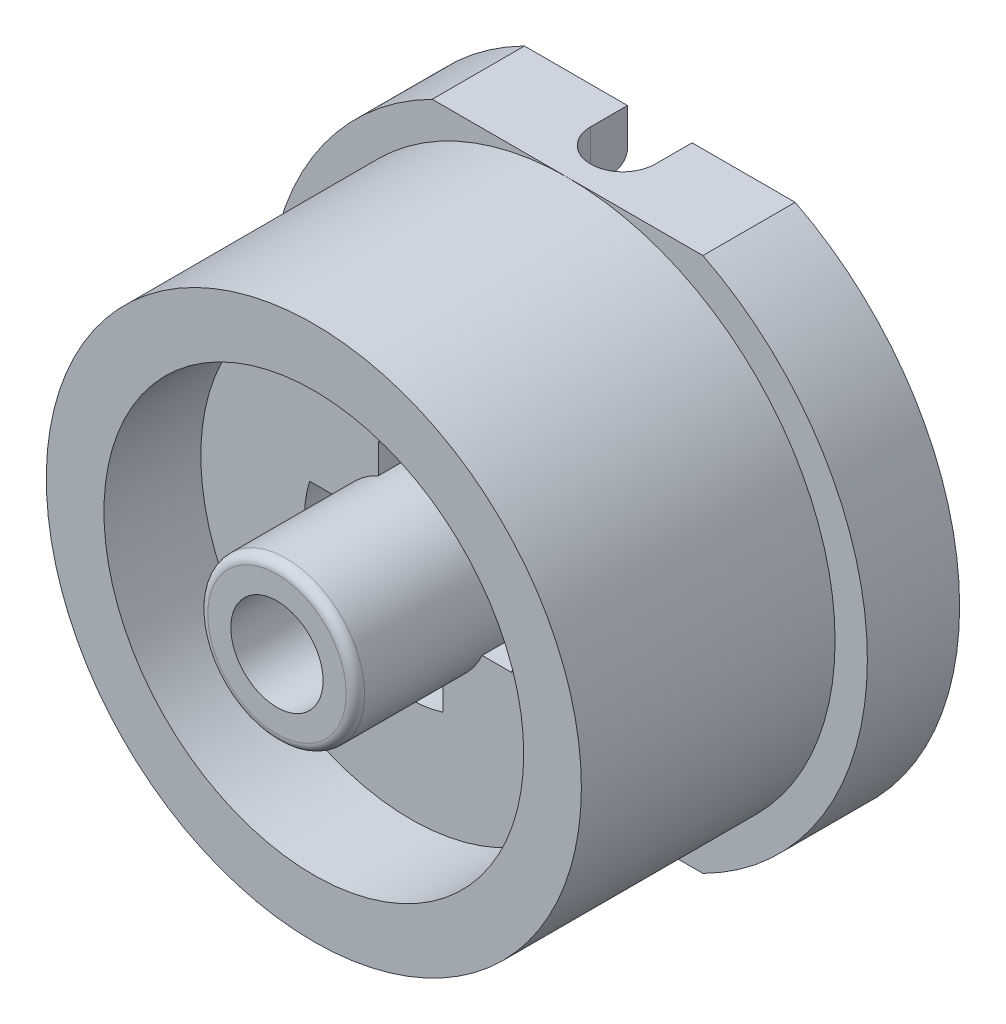
from build123d import *

# Parameters (mm, degrees)
SKETCH_1_R               = 5.8
SKETCH_1_R_2             = 4.55
EXTRUDE_1_DEPTH          = 2.1
SKETCH_1_3_R             = 1.7
SKETCH_1_3_R_2           = 1
EXTRUDE_2_DEPTH          = 2.9
SKETCH_1_5_R             = 5.8
SKETCH_1_5_R_2           = 4.55
SKETCH_1_5_R_3           = 1.7
SKETCH_1_5_R_4           = 1
EXTRUDE_4_DEPTH          = 0.8
SKETCH_2_R               = 5.8
SKETCH_2_R_2             = 4.75
EXTRUDE_5_DEPTH          = 4.6
EXTRUDE_6_DEPTH          = 2
CUT_EXTRUDE_1_REACH      = 11.851
FILLET_1_R               = 0.2
FILLET_2_R               = 0.3
SKETCH_6_R               = 1.15
CUT_EXTRUDE_4_DEPTH      = 0.5
CUT_EXTRUDE_5_REACH      = 16.352
CUT_EXTRUDE_5_END_RADIUS = 4.75


with BuildPart() as part:
    # Sketch 1 → Extrude 1 (new body)
    with BuildSketch(Plane.XY):
        Circle(SKETCH_1_R)
        Circle(SKETCH_1_R_2, mode=Mode.SUBTRACT)
    extrude(amount=EXTRUDE_1_DEPTH)



with BuildPart() as body_2:
    # Sketch 1_3 → Extrude 2 (new body)
    with BuildSketch(Plane.XY):
        Circle(SKETCH_1_3_R)
        Circle(SKETCH_1_3_R_2, mode=Mode.SUBTRACT)
    extrude(amount=EXTRUDE_2_DEPTH)


with BuildPart() as part_1:
    add(part.part)

    add(body_2.part)  # Extrude 4 merges body 2
    # Sketch 1_5 → Extrude 4 (add)
    with BuildSketch(Plane.XY):
        Circle(SKETCH_1_5_R)
        Circle(SKETCH_1_5_R_2, mode=Mode.SUBTRACT)
        Circle(SKETCH_1_5_R_2)
        Circle(SKETCH_1_5_R_3, mode=Mode.SUBTRACT)
        Circle(SKETCH_1_5_R_3)
        Circle(SKETCH_1_5_R_4, mode=Mode.SUBTRACT)
    extrude(amount=-EXTRUDE_4_DEPTH)

    # Sketch 2 → Extrude 5 (add)
    with BuildSketch(Plane(origin=(0, 0, -0.8), x_dir=(-1, 0, 0), z_dir=(0, 0, -1))):
        Circle(SKETCH_2_R)
        Circle(SKETCH_2_R_2, mode=Mode.SUBTRACT)
    extrude(amount=EXTRUDE_5_DEPTH)

    # Sketch 3 → Extrude 6 (add)
    with BuildSketch(Plane(origin=(0, 0, -5.4), x_dir=(-1, 0, 0), z_dir=(0, 0, -1))):
        with BuildLine():
            Line((0, 5.8), (-2.93428015, 5.8))
            ThreePointArc((-2.93428015, 5.8), (-6.5, 0), (-2.93428015, -5.8))
            Line((-2.93428015, -5.8), (0, -5.8))
            ThreePointArc((0, -5.8), (-5.8, 0), (0, 5.8))
        make_face()
        with BuildLine():
            Line((2.93428015, 5.8), (0, 5.8))
            ThreePointArc((0, 5.8), (5.8, 0), (0, -5.8))
            Line((0, -5.8), (2.93428015, -5.8))
            ThreePointArc((2.93428015, -5.8), (6.5, 0), (2.93428015, 5.8))
        make_face()
    extrude(amount=-EXTRUDE_6_DEPTH)

    # Sketch 4 → Cut-Extrude 1 (cut, up to next)
    with BuildSketch(Plane(origin=(0, 0, -0.8), x_dir=(-1, 0, 0), z_dir=(0, 0, -1)), mode=Mode.PRIVATE) as cut_extrude_1_sk1:
        with BuildLine():
            Line((-0.7, -1.549193338), (-0.7, -2.19089023))
            ThreePointArc((-0.7, -2.19089023), (0, -2.3), (0.7, -2.19089023))
            Line((0.7, -2.19089023), (0.7, -1.549193338))
            ThreePointArc((0.7, -1.549193338), (0, -1.7), (-0.7, -1.549193338))
        make_face()
    cut_extrude_1_tool1 = extrude(cut_extrude_1_sk1.sketch, amount=-CUT_EXTRUDE_1_REACH, mode=Mode.PRIVATE) & part_1.part
    # Sketch 4 → Cut-Extrude 1 (cut, up to next)
    with BuildSketch(Plane(origin=(0, 0, -0.8), x_dir=(-1, 0, 0), z_dir=(0, 0, -1)), mode=Mode.PRIVATE) as cut_extrude_1_sk2:
        with BuildLine():
            ThreePointArc((0.7, 2.19089023), (0, 2.3), (-0.7, 2.19089023))
            Line((-0.7, 2.19089023), (-0.7, 1.549193338))
            ThreePointArc((-0.7, 1.549193338), (0, 1.7), (0.7, 1.549193338))
            Line((0.7, 1.549193338), (0.7, 2.19089023))
        make_face()
    cut_extrude_1_tool2 = extrude(cut_extrude_1_sk2.sketch, amount=-CUT_EXTRUDE_1_REACH, mode=Mode.PRIVATE) & part_1.part
    # Sketch 4 → Cut-Extrude 1 (cut, up to next)
    with BuildSketch(Plane(origin=(0, 0, -0.8), x_dir=(-1, 0, 0), z_dir=(0, 0, -1)), mode=Mode.PRIVATE) as cut_extrude_1_sk3:
        with BuildLine():
            ThreePointArc((-2.19089023, 0.7), (-2.3, 0), (-2.19089023, -0.7))
            Line((-2.19089023, -0.7), (-1.549193338, -0.7))
            ThreePointArc((-1.549193338, -0.7), (-1.7, 0), (-1.549193338, 0.7))
            Line((-1.549193338, 0.7), (-2.19089023, 0.7))
        make_face()
    cut_extrude_1_tool3 = extrude(cut_extrude_1_sk3.sketch, amount=-CUT_EXTRUDE_1_REACH, mode=Mode.PRIVATE) & part_1.part
    # Sketch 4 → Cut-Extrude 1 (cut, up to next)
    with BuildSketch(Plane(origin=(0, 0, -0.8), x_dir=(-1, 0, 0), z_dir=(0, 0, -1)), mode=Mode.PRIVATE) as cut_extrude_1_sk4:
        with BuildLine():
            Line((1.549193338, -0.7), (2.19089023, -0.7))
            ThreePointArc((2.19089023, -0.7), (2.272558858, -0.354226249), (2.3, 0))
            ThreePointArc((2.3, 0), (2.272558858, 0.354226249), (2.19089023, 0.7))
            Line((2.19089023, 0.7), (1.549193338, 0.7))
            ThreePointArc((1.549193338, 0.7), (1.661870734, 0.358030253), (1.7, 0))
            ThreePointArc((1.7, 0), (1.661870734, -0.358030253), (1.549193338, -0.7))
        make_face()
    cut_extrude_1_tool4 = extrude(cut_extrude_1_sk4.sketch, amount=-CUT_EXTRUDE_1_REACH, mode=Mode.PRIVATE) & part_1.part
    # Sketch 4 → Cut-Extrude 1 (cut, up to next)
    with BuildSketch(Plane(origin=(0, 0, -0.8), x_dir=(-1, 0, 0), z_dir=(0, 0, -1)), mode=Mode.PRIVATE) as cut_extrude_1_sk5:
        with BuildLine():
            Line((-0.7, -1.549193338), (-0.7, -2.19089023))
            ThreePointArc((-0.7, -2.19089023), (0, -2.3), (0.7, -2.19089023))
            Line((0.7, -2.19089023), (0.7, -1.549193338))
            ThreePointArc((0.7, -1.549193338), (0, -1.7), (-0.7, -1.549193338))
        make_face()
    cut_extrude_1_tool5 = extrude(cut_extrude_1_sk5.sketch, amount=-CUT_EXTRUDE_1_REACH, mode=Mode.PRIVATE) & part_1.part
    # Sketch 4 → Cut-Extrude 1 (cut, up to next)
    with BuildSketch(Plane(origin=(0, 0, -0.8), x_dir=(-1, 0, 0), z_dir=(0, 0, -1)), mode=Mode.PRIVATE) as cut_extrude_1_sk6:
        with BuildLine():
            ThreePointArc((0.7, 2.19089023), (0, 2.3), (-0.7, 2.19089023))
            Line((-0.7, 2.19089023), (-0.7, 1.549193338))
            ThreePointArc((-0.7, 1.549193338), (0, 1.7), (0.7, 1.549193338))
            Line((0.7, 1.549193338), (0.7, 2.19089023))
        make_face()
    cut_extrude_1_tool6 = extrude(cut_extrude_1_sk6.sketch, amount=-CUT_EXTRUDE_1_REACH, mode=Mode.PRIVATE) & part_1.part
    # Sketch 4 → Cut-Extrude 1 (cut, up to next)
    with BuildSketch(Plane(origin=(0, 0, -0.8), x_dir=(-1, 0, 0), z_dir=(0, 0, -1)), mode=Mode.PRIVATE) as cut_extrude_1_sk7:
        with BuildLine():
            ThreePointArc((-2.19089023, 0.7), (-2.3, 0), (-2.19089023, -0.7))
            Line((-2.19089023, -0.7), (-1.549193338, -0.7))
            ThreePointArc((-1.549193338, -0.7), (-1.7, 0), (-1.549193338, 0.7))
            Line((-1.549193338, 0.7), (-2.19089023, 0.7))
        make_face()
    cut_extrude_1_tool7 = extrude(cut_extrude_1_sk7.sketch, amount=-CUT_EXTRUDE_1_REACH, mode=Mode.PRIVATE) & part_1.part
    # Sketch 4 → Cut-Extrude 1 (cut, up to next)
    with BuildSketch(Plane(origin=(0, 0, -0.8), x_dir=(-1, 0, 0), z_dir=(0, 0, -1)), mode=Mode.PRIVATE) as cut_extrude_1_sk8:
        with BuildLine():
            Line((1.549193338, -0.7), (2.19089023, -0.7))
            ThreePointArc((2.19089023, -0.7), (2.272558858, -0.354226249), (2.3, 0))
            ThreePointArc((2.3, 0), (2.272558858, 0.354226249), (2.19089023, 0.7))
            Line((2.19089023, 0.7), (1.549193338, 0.7))
            ThreePointArc((1.549193338, 0.7), (1.661870734, 0.358030253), (1.7, 0))
            ThreePointArc((1.7, 0), (1.661870734, -0.358030253), (1.549193338, -0.7))
        make_face()
    cut_extrude_1_tool8 = extrude(cut_extrude_1_sk8.sketch, amount=-CUT_EXTRUDE_1_REACH, mode=Mode.PRIVATE) & part_1.part
    add(cut_extrude_1_tool1.solids().sort_by_distance((0, -1.956551, -0.8))[0], mode=Mode.SUBTRACT)
    add(cut_extrude_1_tool2.solids().sort_by_distance((0, 1.956551, -0.8))[0], mode=Mode.SUBTRACT)
    add(cut_extrude_1_tool3.solids().sort_by_distance((1.956551, 0, -0.8))[0], mode=Mode.SUBTRACT)
    add(cut_extrude_1_tool4.solids().sort_by_distance((-1.956551, 0, -0.8))[0], mode=Mode.SUBTRACT)
    add(cut_extrude_1_tool5.solids().sort_by_distance((0, -1.956551, -0.8))[0], mode=Mode.SUBTRACT)
    add(cut_extrude_1_tool6.solids().sort_by_distance((0, 1.956551, -0.8))[0], mode=Mode.SUBTRACT)
    add(cut_extrude_1_tool7.solids().sort_by_distance((1.956551, 0, -0.8))[0], mode=Mode.SUBTRACT)
    add(cut_extrude_1_tool8.solids().sort_by_distance((-1.956551, 0, -0.8))[0], mode=Mode.SUBTRACT)

    # Fillet 1
    fillet_1_edges = [part_1.edges().sort_by_distance(p)[0] for p in [
        (-1.7, 0, 2.9),
    ]]
    fillet(fillet_1_edges, radius=FILLET_1_R)

    # Fillet 2
    fillet_2_edges = [part_1.edges().sort_by_distance(p)[0] for p in [
        (4.75, 0, -5.4),
    ]]
    fillet(fillet_2_edges, radius=FILLET_2_R)

    # Sketch 6 → Cut-Extrude 4 (cut)
    with BuildSketch(Plane(origin=(0, 0, -0.8), x_dir=(-1, 0, 0), z_dir=(0, 0, -1))):
        Circle(SKETCH_6_R)
    extrude(amount=-CUT_EXTRUDE_4_DEPTH, mode=Mode.SUBTRACT)

    # Cut-Extrude 5: up to this cylinder (the profile starts outside it)
    cut_extrude_5_end = Plane(origin=(0, 0, -4.843393), z_dir=(0, 0, 1)) * Cylinder(CUT_EXTRUDE_5_END_RADIUS, 44.284964, mode=Mode.PRIVATE)
    # Sketch 7 → Cut-Extrude 5 (cut, up to the surface)
    with BuildSketch(Plane(origin=(0, 5.8, 0), x_dir=(1, 0, 0), z_dir=(0, 1, 0)), mode=Mode.PRIVATE) as cut_extrude_5_sk1:
        with BuildLine():
            Line((-0.7, 5.4), (-0.7, 4.6))
            ThreePointArc((-0.7, 4.6), (0, 5.3), (0.7, 4.6))
            Line((0.7, 4.6), (0.7, 5.4))
            Line((0.7, 5.4), (-0.7, 5.4))
        make_face()
    cut_extrude_5_tool1 = extrude(cut_extrude_5_sk1.sketch, amount=-CUT_EXTRUDE_5_REACH, mode=Mode.PRIVATE) - cut_extrude_5_end
    add(cut_extrude_5_tool1.solids().sort_by_distance((0, 5.8, -5.383875))[0], mode=Mode.SUBTRACT)
    # Sketch 7 → Cut-Extrude 5 (cut, up to the surface)
    with BuildSketch(Plane(origin=(0, 5.8, 0), x_dir=(1, 0, 0), z_dir=(0, 1, 0)), mode=Mode.PRIVATE) as cut_extrude_5_sk2:
        with BuildLine():
            ThreePointArc((0.7, 4.6), (0, 5.3), (-0.7, 4.6))
            Line((-0.7, 4.6), (0.7, 4.6))
        make_face()
    cut_extrude_5_tool2 = extrude(cut_extrude_5_sk2.sketch, amount=-CUT_EXTRUDE_5_REACH, mode=Mode.PRIVATE) - cut_extrude_5_end
    add(cut_extrude_5_tool2.solids().sort_by_distance((0, 5.8, -4.897089))[0], mode=Mode.SUBTRACT)
    # Sketch 7 → Cut-Extrude 5 (cut, up to the surface)
    with BuildSketch(Plane(origin=(0, 5.8, 0), x_dir=(1, 0, 0), z_dir=(0, 1, 0)), mode=Mode.PRIVATE) as cut_extrude_5_sk3:
        with BuildLine():
            Line((0.7, 4.6), (-0.7, 4.6))
            ThreePointArc((-0.7, 4.6), (0, 3.9), (0.7, 4.6))
        make_face()
    cut_extrude_5_tool3 = extrude(cut_extrude_5_sk3.sketch, amount=-CUT_EXTRUDE_5_REACH, mode=Mode.PRIVATE) - cut_extrude_5_end
    add(cut_extrude_5_tool3.solids().sort_by_distance((0, 5.8, -4.302911))[0], mode=Mode.SUBTRACT)
    # Sketch 7 → Cut-Extrude 5 (cut, up to the surface)
    with BuildSketch(Plane(origin=(0, 5.8, 0), x_dir=(1, 0, 0), z_dir=(0, 1, 0)), mode=Mode.PRIVATE) as cut_extrude_5_sk4:
        with BuildLine():
            ThreePointArc((0.7, 4.6), (0, 5.3), (-0.7, 4.6))
            Line((-0.7, 4.6), (0.7, 4.6))
        make_face()
    cut_extrude_5_tool4 = extrude(cut_extrude_5_sk4.sketch, amount=-CUT_EXTRUDE_5_REACH, mode=Mode.PRIVATE) - cut_extrude_5_end
    add(cut_extrude_5_tool4.solids().sort_by_distance((0, 5.8, -4.897089))[0], mode=Mode.SUBTRACT)
    # Sketch 7 → Cut-Extrude 5 (cut, up to the surface)
    with BuildSketch(Plane(origin=(0, 5.8, 0), x_dir=(1, 0, 0), z_dir=(0, 1, 0)), mode=Mode.PRIVATE) as cut_extrude_5_sk5:
        with BuildLine():
            Line((0.7, 4.6), (-0.7, 4.6))
            ThreePointArc((-0.7, 4.6), (0, 3.9), (0.7, 4.6))
        make_face()
    cut_extrude_5_tool5 = extrude(cut_extrude_5_sk5.sketch, amount=-CUT_EXTRUDE_5_REACH, mode=Mode.PRIVATE) - cut_extrude_5_end
    add(cut_extrude_5_tool5.solids().sort_by_distance((0, 5.8, -4.302911))[0], mode=Mode.SUBTRACT)


solid = part_1.part
